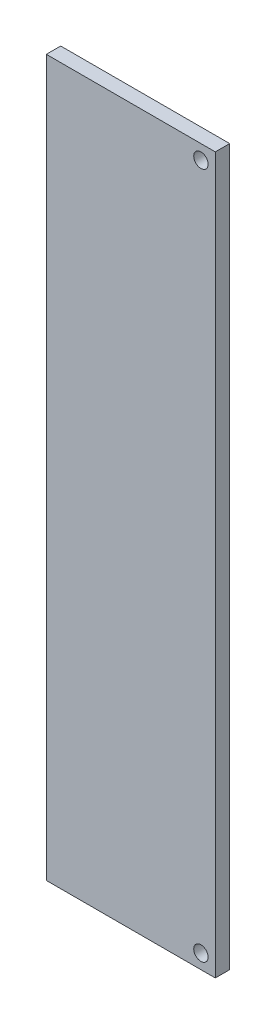
from build123d import *

# Parameters (mm, degrees)
SKETCH1_W           = 23.5
SKETCH1_H           = 99.5
BOSS_EXTRUDE1_DEPTH = 2
SKETCH2_R           = 1
CUT_EXTRUDE1_DEPTH  = 3


with BuildPart() as part:
    # Sketch1 → Boss-Extrude1 (new body)
    with BuildSketch(Plane.XY):
        with Locations((-45.25, -13.75)):
            Rectangle(SKETCH1_W, SKETCH1_H)
    extrude(amount=BOSS_EXTRUDE1_DEPTH)

    # Sketch2 → Cut-Extrude1 (cut, through all)
    with BuildSketch(Plane.XY.offset(2)):
        with Locations((-35.5, 34)):
            Circle(SKETCH2_R)
        with Locations((-35.5, -61.5)):
            Circle(SKETCH2_R)
    extrude(amount=-CUT_EXTRUDE1_DEPTH, mode=Mode.SUBTRACT)


solid = part.part
